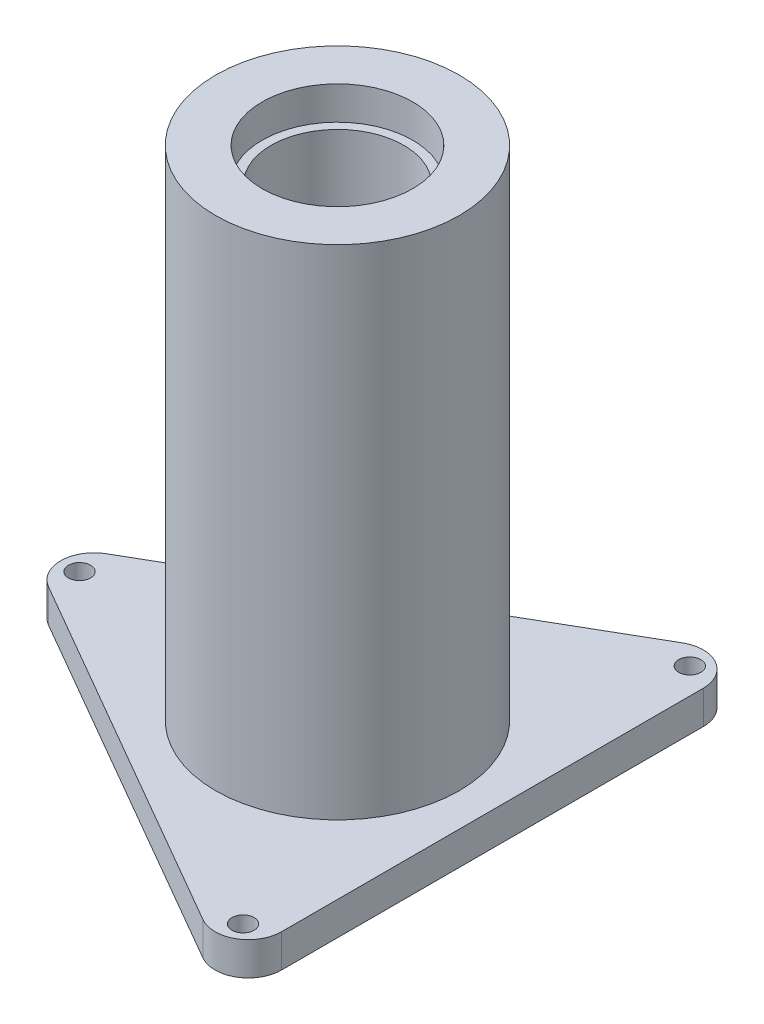
from build123d import *

# Parameters (mm, degrees)
SKETCH2_R           = 6.8
SKETCH2_R_2         = 1
BOSS_EXTRUDE1_DEPTH = 3


with BuildPart() as part:
    # Sketch1 → Revolve1 (revolve)
    with BuildSketch(Plane.XY):
        Polygon((11, 12.28125), (6.8, 12.28125), (6.8, 9.28125), (6, 9.28125), (6, -32.71875), (11, -32.71875), align=None)
    revolve(axis=Axis((0, 17.71875, 0), (0, -1, 0)))

    # Sketch2 → Boss-Extrude1 (add)
    with BuildSketch(Plane.XZ.offset(32.71875)):
        with BuildLine():
            Line((-23.5, -2.598076211), (9.5, -21.650635095))
            ThreePointArc((9.5, -21.650635095), (12.5, -21.650635095), (14, -19.052558883))
            Line((14, -19.052558883), (14, 19.052558883))
            ThreePointArc((14, 19.052558883), (12.5, 21.650635095), (9.5, 21.650635095))
            Line((9.5, 21.650635095), (-23.5, 2.598076211))
            ThreePointArc((-23.5, 2.598076211), (-25, 0), (-23.5, -2.598076211))
        make_face()
        Circle(SKETCH2_R, mode=Mode.SUBTRACT)
        with Locations((11.65, 20.178391908)):
            Circle(SKETCH2_R_2, mode=Mode.SUBTRACT)
        with Locations((-23.3, 0)):
            Circle(SKETCH2_R_2, mode=Mode.SUBTRACT)
        with Locations((11.65, -20.178391908)):
            Circle(SKETCH2_R_2, mode=Mode.SUBTRACT)
    extrude(amount=BOSS_EXTRUDE1_DEPTH)


solid = part.part
